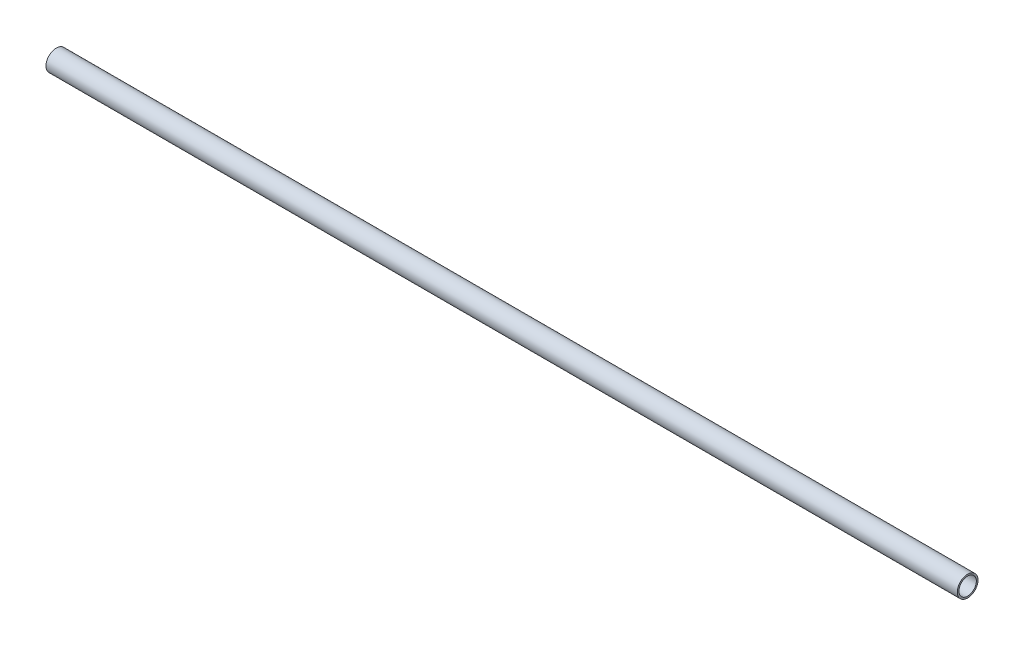
from build123d import *

# Parameters (mm, degrees)
SKETCH1_R           = 6.35
SKETCH1_R_2         = 5.334
BOSS_EXTRUDE1_DEPTH = 558.8


with BuildPart() as part:
    # Sketch1 → Boss-Extrude1 (new body)
    with BuildSketch(Plane(origin=(0, 0, 0), x_dir=(0, 0, -1), z_dir=(1, 0, 0))):
        Circle(SKETCH1_R)
        Circle(SKETCH1_R_2, mode=Mode.SUBTRACT)
    extrude(amount=-BOSS_EXTRUDE1_DEPTH)


solid = part.part
